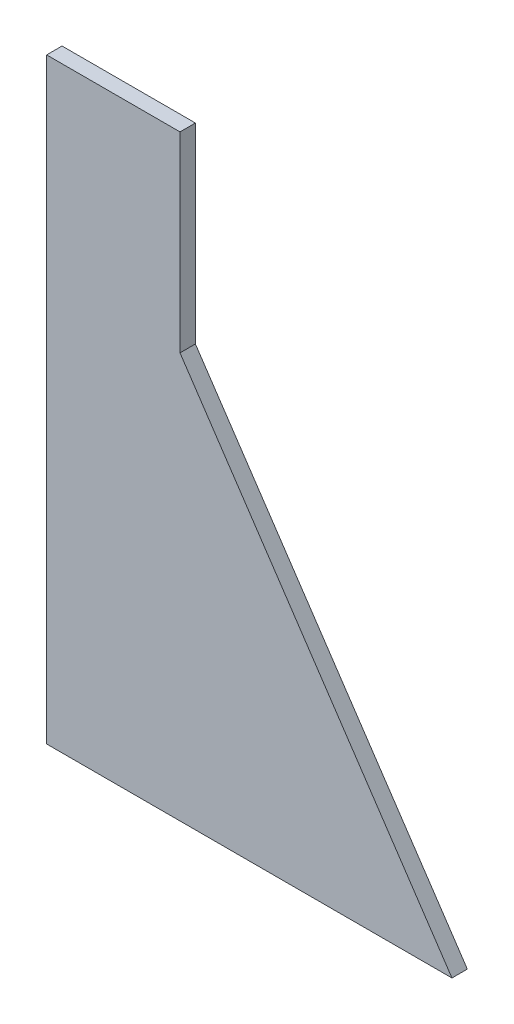
from build123d import *

# Parameters (mm, degrees)
BOSS_EXTRUDE1_DEPTH = 3


with BuildPart() as part:
    # Sketch1 → Boss-Extrude1 (new body)
    with BuildSketch(Plane.XY.offset(-231.833966153)):
        Polygon((0, 0), (0, -116.353177225), (79.018807169, -116.353177225), (26, -37.313053542), (26, 0), align=None)
    extrude(amount=-BOSS_EXTRUDE1_DEPTH)


solid = part.part
